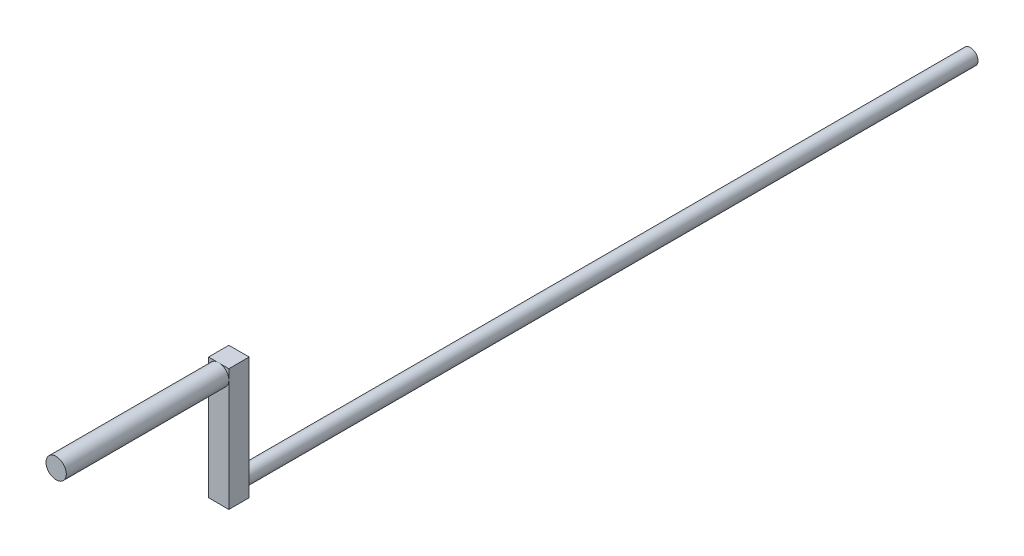
from build123d import *

# Parameters (mm, degrees)
SKETCH1_R           = 2.38125
BOSS_EXTRUDE1_DEPTH = 228.6
SKETCH2_W           = 6.35
SKETCH2_H           = 38.1
BOSS_EXTRUDE2_DEPTH = 6.35
SKETCH3_R           = 3.175
BOSS_EXTRUDE3_DEPTH = 50.8


with BuildPart() as part:
    # Sketch1 → Boss-Extrude1 (new body)
    with BuildSketch(Plane.XY):
        Circle(SKETCH1_R)
    extrude(amount=BOSS_EXTRUDE1_DEPTH)

    # Sketch2 → Boss-Extrude2 (add)
    with BuildSketch(Plane.XY.offset(228.6)):
        with Locations((0.040964163, 15.489894183)):
            Rectangle(SKETCH2_W, SKETCH2_H)
    extrude(amount=BOSS_EXTRUDE2_DEPTH)

    # Sketch3 → Boss-Extrude3 (add)
    with BuildSketch(Plane.XY.offset(234.95)):
        with Locations((0.040964163, 31.442054565)):
            Circle(SKETCH3_R)
    extrude(amount=BOSS_EXTRUDE3_DEPTH)


solid = part.part
